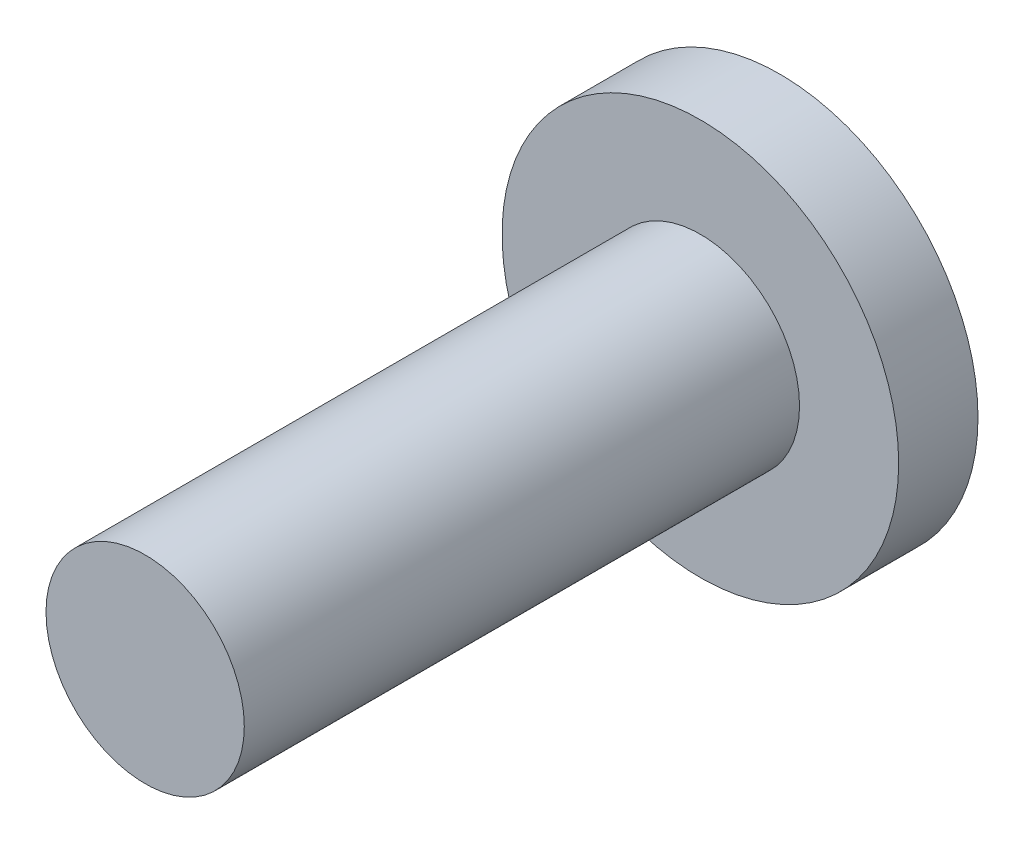
from build123d import *

# Parameters (mm, degrees)
SKETCH1_R           = 1.25
BOSS_EXTRUDE1_DEPTH = 7
SKETCH2_R           = 2.5
BOSS_EXTRUDE2_DEPTH = 1


with BuildPart() as part:
    # Sketch1 → Boss-Extrude1 (new body)
    with BuildSketch(Plane.XY):
        Circle(SKETCH1_R)
    extrude(amount=BOSS_EXTRUDE1_DEPTH)

    # Sketch2 → Boss-Extrude2 (add)
    with BuildSketch(Plane.XY):
        Circle(SKETCH2_R)
    extrude(amount=-BOSS_EXTRUDE2_DEPTH)


solid = part.part
